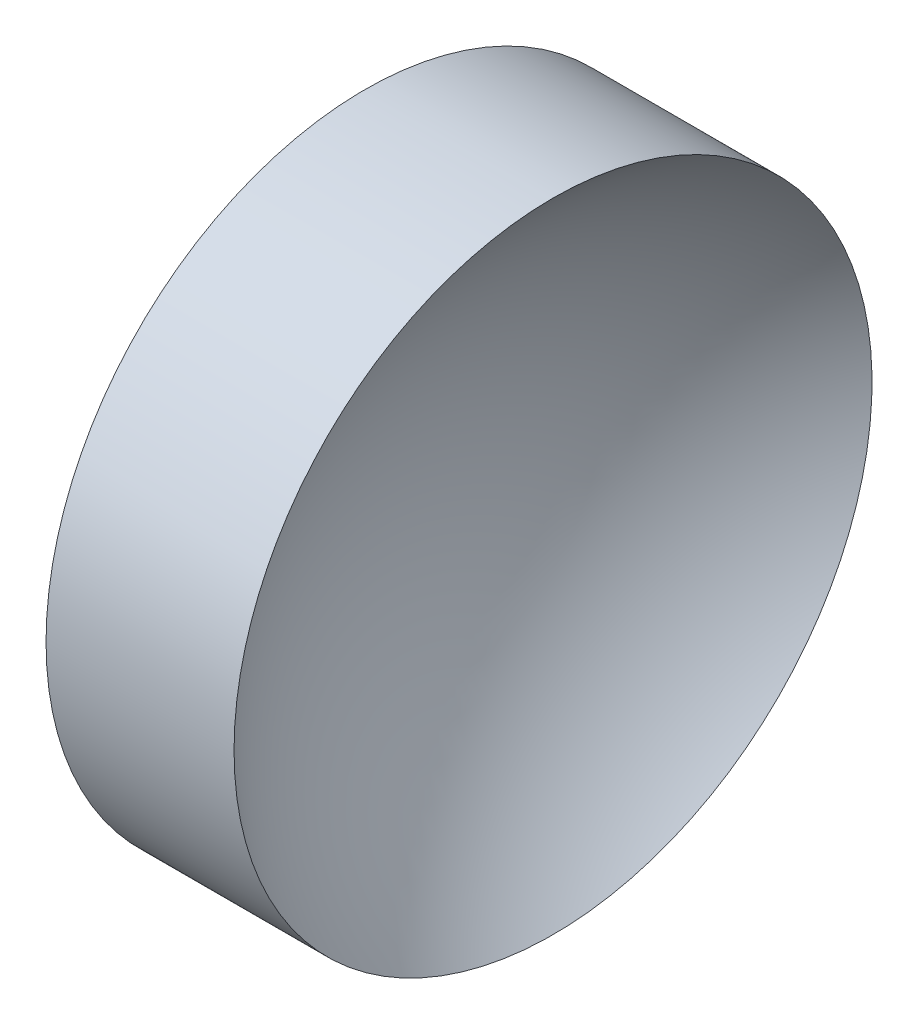
from build123d import *


with BuildPart() as part:
    # 草图1 → 旋转1 (revolve)
    with BuildSketch(Plane.XY):
        with BuildLine():
            Line((113.739437135, 65.155630457), (113.739437135, 90.155630457))
            Line((113.739437135, 90.155630457), (128.472877477, 90.155630457))
            ThreePointArc((128.472877477, 90.155630457), (119.818669054, 78.963903541), (116.739437135, 65.155630457))
            Line((116.739437135, 65.155630457), (113.739437135, 65.155630457))
        make_face()
    revolve(axis=Axis((105.621837124, 65.155630457, 0), (1, 0, 0)))


solid = part.part
